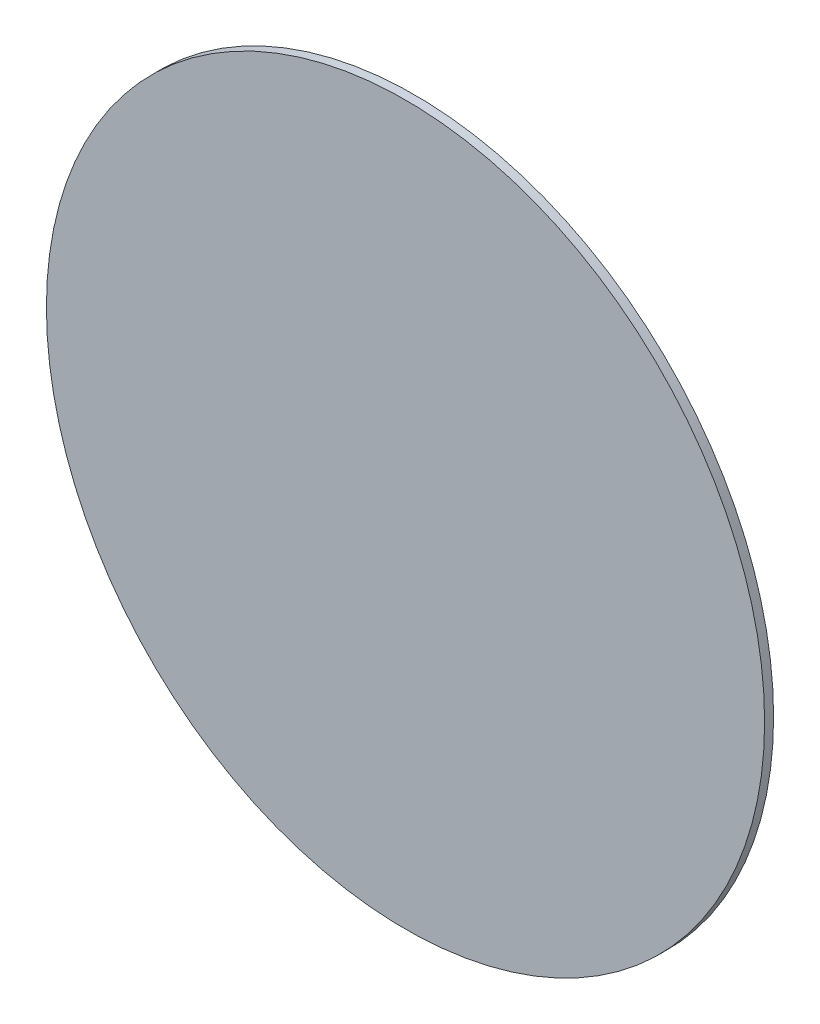
from build123d import *

# Parameters (mm, degrees)
CROQUIS1_R              = 20
SALIENTE_EXTRUIR1_DEPTH = 0.5


with BuildPart() as part:
    # Croquis1 → Saliente-Extruir1 (new body)
    with BuildSketch(Plane.XY):
        Circle(CROQUIS1_R)
    extrude(amount=SALIENTE_EXTRUIR1_DEPTH)


solid = part.part
